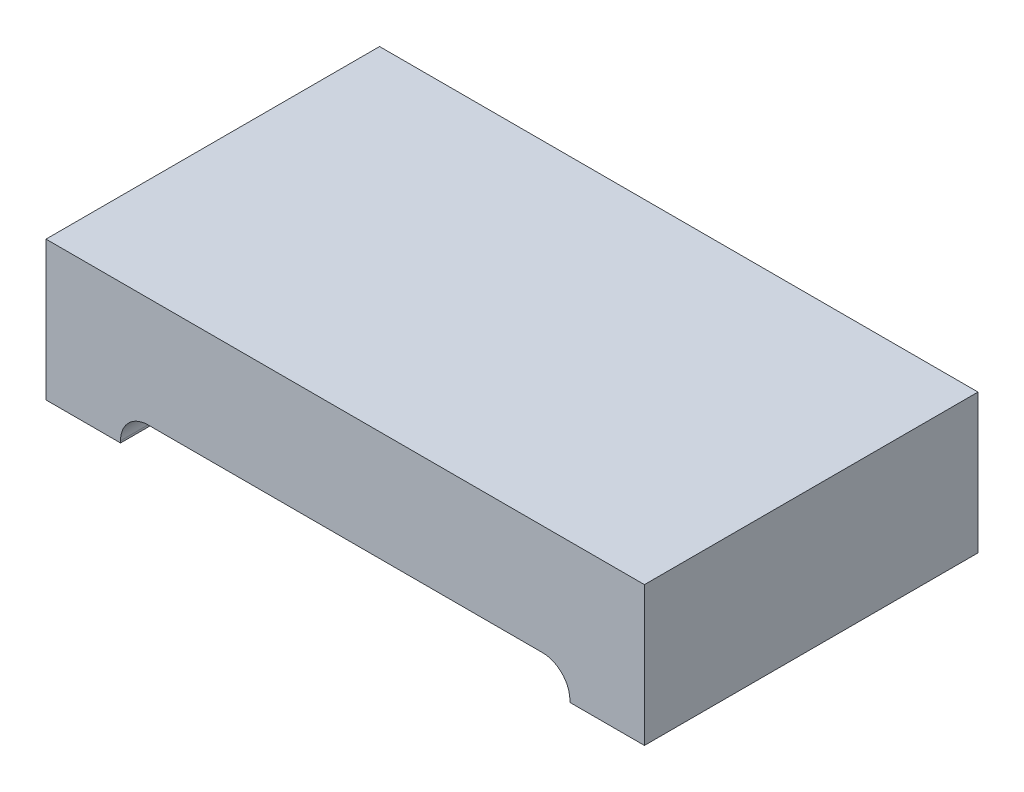
from build123d import *

# Parameters (mm, degrees)
SKETCH1_W               = 3.05
SKETCH1_H               = 1.7
BOSS_EXTRUDE1_DEPTH     = 0.71
CUT_EXTRUDE1_DEPTH      = 1.85
CUT_EXTRUDE1_DEPTH_BACK = 1.85


with BuildPart() as part:
    # Sketch1 → Boss-Extrude1 (new body)
    with BuildSketch(Plane(origin=(0, 0, 0), x_dir=(1, 0, 0), z_dir=(0, 1, 0))):
        Rectangle(SKETCH1_W, SKETCH1_H)
    extrude(amount=BOSS_EXTRUDE1_DEPTH)

    # Sketch2 → Cut-Extrude1 (cut, two sides)
    with BuildSketch(Plane.XY) as cut_extrude1_sk:
        with BuildLine():
            Line((-1.145, 0), (1.145, 0))
            Line((1.145, 0), (1.145, 0.01))
            ThreePointArc((1.145, 0.01), (1.103994949, 0.108994949), (1.005, 0.15))
            Line((1.005, 0.15), (-1.005, 0.15))
            ThreePointArc((-1.005, 0.15), (-1.103994949, 0.108994949), (-1.145, 0.01))
            Line((-1.145, 0.01), (-1.145, 0))
        make_face()
    extrude(amount=CUT_EXTRUDE1_DEPTH, mode=Mode.SUBTRACT)
    extrude(cut_extrude1_sk.sketch, amount=-CUT_EXTRUDE1_DEPTH_BACK, mode=Mode.SUBTRACT)


solid = part.part
